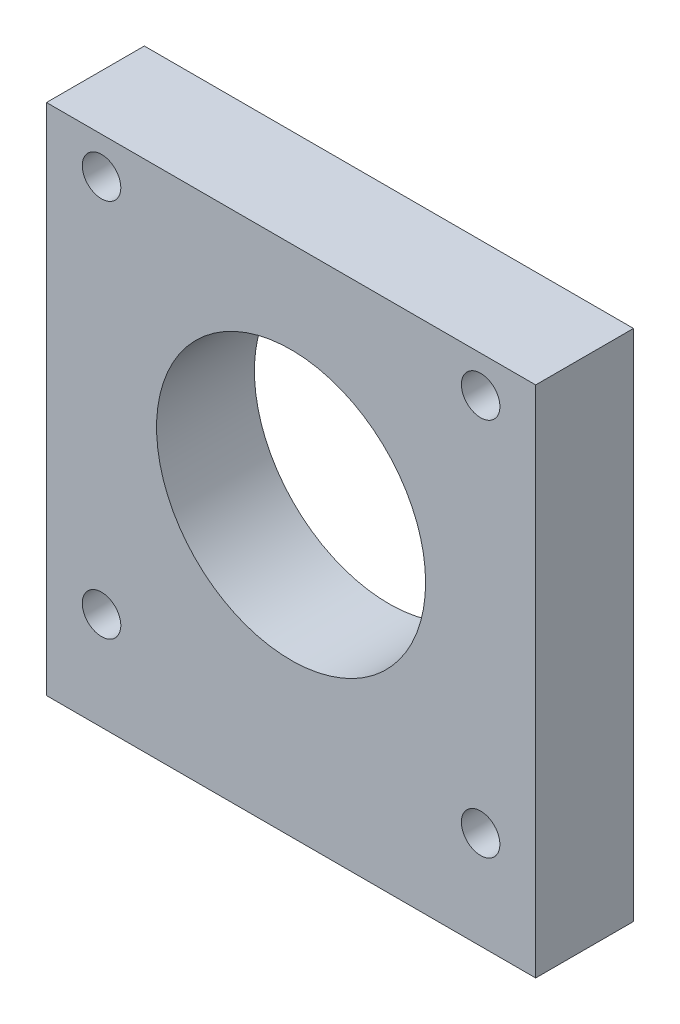
from build123d import *

# Parameters (mm, degrees)
ESBO_O1_W                                         = 40
ESBO_O1_H                                         = 42
RESSALTO_EXTRUS_O1_DEPTH                          = 8
ESBO_O2_R                                         = 11
CORTE_EXTRUS_O1_DEPTH                             = 9
FURO_ROSCADO_PARA_CONDU_TE_DE_M3X0_51_D           = 3.15
FURO_ROSCADO_PARA_CONDU_TE_DE_M3X0_51_DEPTH       = 10
FURO_ROSCADO_PARA_CONDU_TE_DE_M3X0_51_CSINK_D     = 3.766
FURO_ROSCADO_PARA_CONDU_TE_DE_M3X0_51_CSINK_ANGLE = 90
FURO_ROSCADO_PARA_CONDU_TE_DE_M3X0_51_TIP         = 0.946355475
FURO_ROSCADO_PARA_CONDU_TE_DE_M3X0_52_D           = 3.15
FURO_ROSCADO_PARA_CONDU_TE_DE_M3X0_52_CSINK_D     = 3.766
FURO_ROSCADO_PARA_CONDU_TE_DE_M3X0_52_CSINK_ANGLE = 90


with BuildPart() as part:
    # Esboço1 → Ressalto-extrusão1 (new body)
    with BuildSketch(Plane.XY):
        Rectangle(ESBO_O1_W, ESBO_O1_H)
    extrude(amount=RESSALTO_EXTRUS_O1_DEPTH)

    # Esboço2 → Corte-extrusão1 (cut, through all)
    with BuildSketch(Plane.XY.offset(8)):
        with Locations((0, 2.5)):
            Circle(ESBO_O2_R)
    extrude(amount=-CORTE_EXTRUS_O1_DEPTH, mode=Mode.SUBTRACT)

    # Furo roscado para conduíte de M3x0.51
    with Locations(Plane(origin=(0, -21, 0), x_dir=(-1, 0, 0), z_dir=(0, -1, 0))):
        with Locations((-12, -4), (12, -4)):
            CounterSinkHole(FURO_ROSCADO_PARA_CONDU_TE_DE_M3X0_51_D / 2, FURO_ROSCADO_PARA_CONDU_TE_DE_M3X0_51_CSINK_D / 2, depth=FURO_ROSCADO_PARA_CONDU_TE_DE_M3X0_51_DEPTH, counter_sink_angle=FURO_ROSCADO_PARA_CONDU_TE_DE_M3X0_51_CSINK_ANGLE)
            with Locations((0, 0, -(FURO_ROSCADO_PARA_CONDU_TE_DE_M3X0_51_DEPTH + FURO_ROSCADO_PARA_CONDU_TE_DE_M3X0_51_TIP / 2))):  # 118° drill point
                Cone(0, FURO_ROSCADO_PARA_CONDU_TE_DE_M3X0_51_D / 2, FURO_ROSCADO_PARA_CONDU_TE_DE_M3X0_51_TIP, mode=Mode.SUBTRACT)

    # Furo roscado para conduíte de M3x0.52 (through all)
    with Locations(Plane(origin=(0, 0, 0), x_dir=(-1, 0, 0), z_dir=(0, 0, -1))):
        with Locations((-15.5, 18), (15.5, 18), (-15.5, -13), (15.5, -13)):
            CounterSinkHole(FURO_ROSCADO_PARA_CONDU_TE_DE_M3X0_52_D / 2, FURO_ROSCADO_PARA_CONDU_TE_DE_M3X0_52_CSINK_D / 2, counter_sink_angle=FURO_ROSCADO_PARA_CONDU_TE_DE_M3X0_52_CSINK_ANGLE)


solid = part.part
